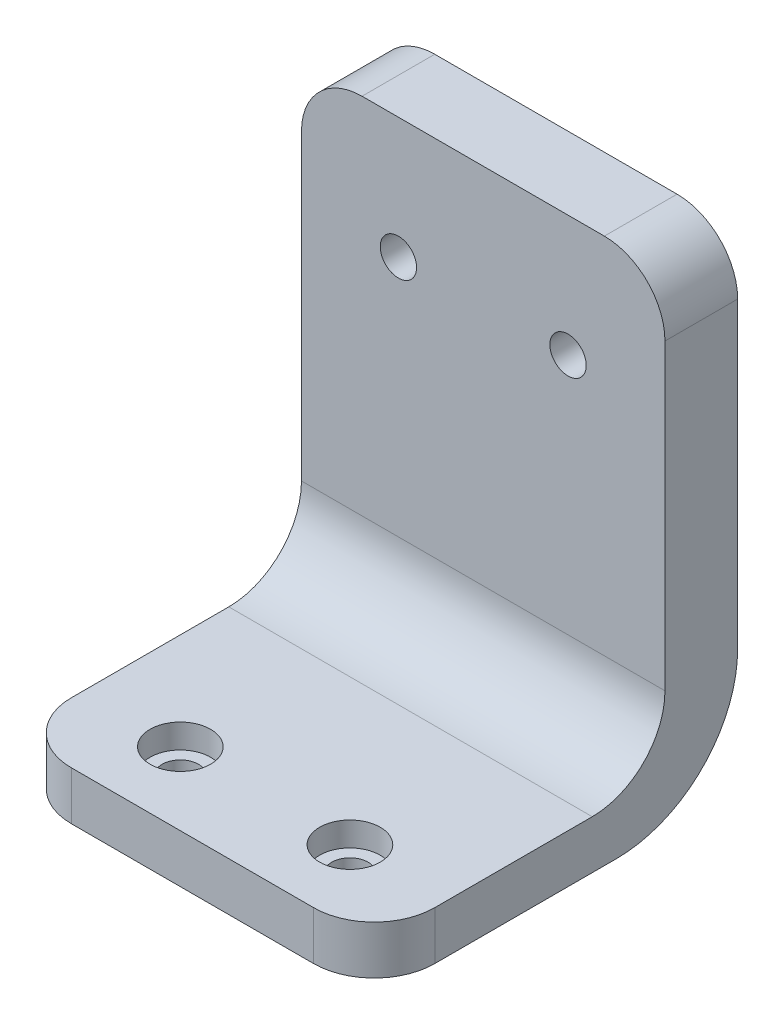
from build123d import *

# Parameters (mm, degrees)
BOSS_EXTRUDE2_DEPTH = 30
FILLET1_R           = 5
CUT_EXTRUDE1_REACH  = 54.65
SKETCH6_R           = 1.5
SKETCH6_3_R         = 2.5
CUT_EXTRUDE2_DEPTH  = 2
CUT_EXTRUDE3_REACH  = 47.837
SKETCH8_R           = 1.5


with BuildPart() as part:
    # Sketch3 → Boss-Extrude2 (new body)
    with BuildSketch(Plane(origin=(0, 0, 0), x_dir=(0, 0, -1), z_dir=(1, 0, 0))):
        with BuildLine():
            Line((0, 15), (0, -15))
            ThreePointArc((0, -15), (-1.757359313, -19.242640687), (-6, -21))
            Line((-6, -21), (-24, -21))
            Line((-24, -21), (-24, -25))
            Line((-24, -25), (-4, -25))
            ThreePointArc((-4, -25), (3.071067812, -22.071067812), (6, -15))
            Line((6, -15), (6, 15))
            Line((6, 15), (0, 15))
        make_face()
    extrude(amount=BOSS_EXTRUDE2_DEPTH)

    # Fillet1
    fillet1_edges = [part.edges().sort_by_distance(p)[0] for p in [
        (30, 15, -3),
        (0, 15, -3),
        (30, -23, 24),
        (0, -23, 24),
    ]]
    fillet(fillet1_edges, radius=FILLET1_R)

    # Sketch6 → Cut-Extrude1 (cut, up to next)
    with BuildSketch(Plane(origin=(0, -21, 0), x_dir=(1, 0, 0), z_dir=(0, 1, 0)), mode=Mode.PRIVATE) as cut_extrude1_sk1:
        with Locations((8, -18)):
            Circle(SKETCH6_R)
    cut_extrude1_tool1 = extrude(cut_extrude1_sk1.sketch, amount=-CUT_EXTRUDE1_REACH, mode=Mode.PRIVATE) & part.part
    # Sketch6 → Cut-Extrude1 (cut, up to next)
    with BuildSketch(Plane(origin=(0, -21, 0), x_dir=(1, 0, 0), z_dir=(0, 1, 0)), mode=Mode.PRIVATE) as cut_extrude1_sk2:
        with Locations((22, -18)):
            Circle(SKETCH6_R)
    cut_extrude1_tool2 = extrude(cut_extrude1_sk2.sketch, amount=-CUT_EXTRUDE1_REACH, mode=Mode.PRIVATE) & part.part
    add(cut_extrude1_tool1.solids().sort_by_distance((8, -21, 18))[0], mode=Mode.SUBTRACT)
    add(cut_extrude1_tool2.solids().sort_by_distance((22, -21, 18))[0], mode=Mode.SUBTRACT)

    # Sketch6_3 → Cut-Extrude2 (cut)
    with BuildSketch(Plane(origin=(0, -21, 0), x_dir=(1, 0, 0), z_dir=(0, 1, 0))):
        with Locations((8, -18)):
            Circle(SKETCH6_3_R)
        with Locations((22, -18)):
            Circle(SKETCH6_3_R)
    extrude(amount=-CUT_EXTRUDE2_DEPTH, mode=Mode.SUBTRACT)

    # Sketch8 → Cut-Extrude3 (cut, up to next)
    with BuildSketch(Plane.XY, mode=Mode.PRIVATE) as cut_extrude3_sk1:
        with Locations((8, 5)):
            Circle(SKETCH8_R)
    cut_extrude3_tool1 = extrude(cut_extrude3_sk1.sketch, amount=-CUT_EXTRUDE3_REACH, mode=Mode.PRIVATE) & part.part
    # Sketch8 → Cut-Extrude3 (cut, up to next)
    with BuildSketch(Plane.XY, mode=Mode.PRIVATE) as cut_extrude3_sk2:
        with Locations((22, 5)):
            Circle(SKETCH8_R)
    cut_extrude3_tool2 = extrude(cut_extrude3_sk2.sketch, amount=-CUT_EXTRUDE3_REACH, mode=Mode.PRIVATE) & part.part
    add(cut_extrude3_tool1.solids().sort_by_distance((8, 5, 0))[0], mode=Mode.SUBTRACT)
    add(cut_extrude3_tool2.solids().sort_by_distance((22, 5, 0))[0], mode=Mode.SUBTRACT)


solid = part.part
